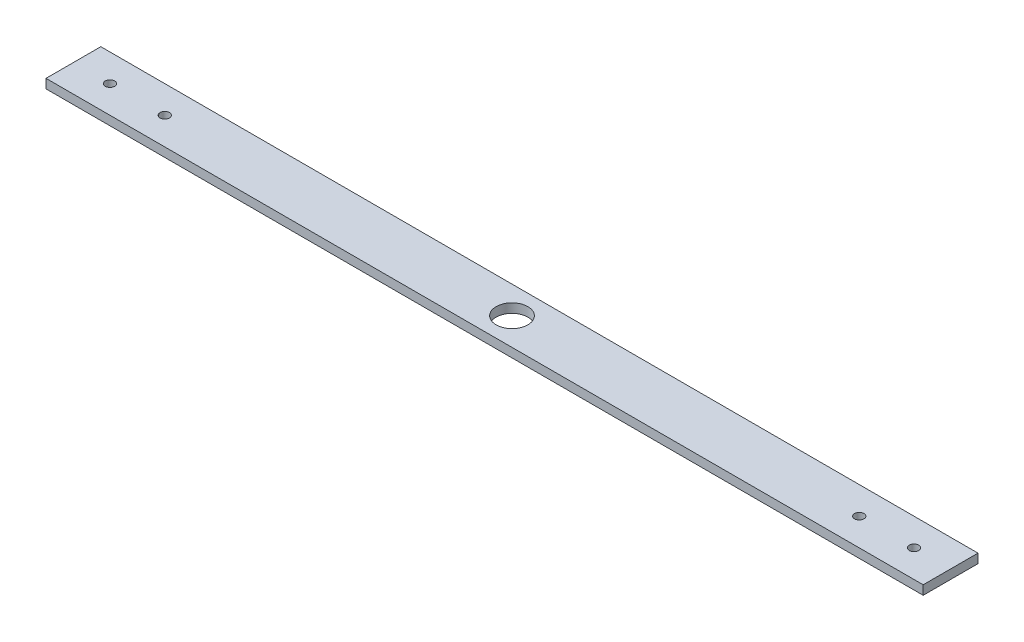
from build123d import *

# Parameters (mm, degrees)
SKETCH1_W                = 609.6
SKETCH1_H                = 38.1
BOSS_EXTRUDE1_DEPTH      = 6.35
SKETCH2_R                = 11
CUT_EXTRUDE1_DEPTH       = 7.62
F_0_257_DIAMETER_HOLE2_D = 6.5278


with BuildPart() as part:
    # Sketch1 → Boss-Extrude1 (new body)
    with BuildSketch(Plane(origin=(0, 0, 0), x_dir=(1, 0, 0), z_dir=(0, 1, 0))):
        Rectangle(SKETCH1_W, SKETCH1_H)
    extrude(amount=BOSS_EXTRUDE1_DEPTH)

    # Sketch2 → Cut-Extrude1 (cut)
    with BuildSketch(Plane(origin=(0, 6.35, 0), x_dir=(1, 0, 0), z_dir=(0, 1, 0))):
        Circle(SKETCH2_R)
    extrude(amount=-CUT_EXTRUDE1_DEPTH, mode=Mode.SUBTRACT)

    # F (0.257) Diameter Hole2 (through all)
    with Locations(Plane(origin=(0, 6.35, 0), x_dir=(1, 0, 0), z_dir=(0, 1, 0))):
        with Locations((-241.3, 0), (-279.4, 0)):
            f_0_257_diameter_hole2 = Hole(F_0_257_DIAMETER_HOLE2_D / 2)

    # Mirror1: F (0.257) Diameter Hole2 across plane
    add(f_0_257_diameter_hole2.mirror(Plane(origin=(0, 0, 0), x_dir=(0, 0, 1), z_dir=(1, 0, 0))), mode=Mode.SUBTRACT)


solid = part.part
